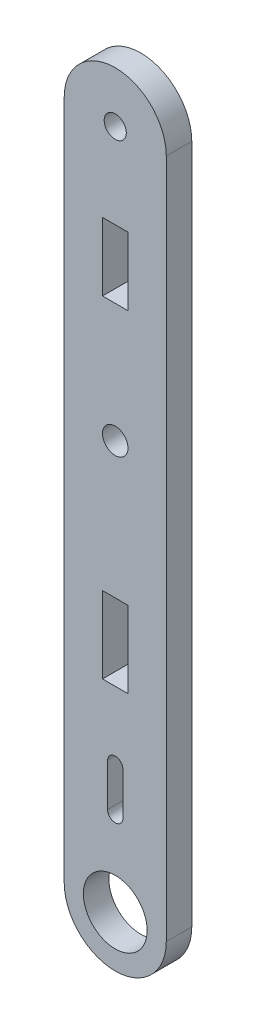
from build123d import *

# Parameters (mm, degrees)
MODEL_R             = 3.750000001
MODEL_R_2           = 1.300000002
MODEL_R_3           = 1.500000002
MODEL_W             = 3
MODEL_H             = 9
MODEL_H_2           = 8
BOSS_EXTRUDE1_DEPTH = 3


with BuildPart() as part:
    # Model → Boss-Extrude1 (new body)
    with BuildSketch(Plane.XY):
        with BuildLine():
            Line((56.05776, -3.869466211), (56.05776, 76.130633789))
            ThreePointArc((56.05776, 76.130633789), (62.05781, 82.130583788), (68.05776, 76.130533788))
            Line((68.05776, 76.130533788), (68.05776, -3.869466211))
            ThreePointArc((68.05776, -3.869466211), (62.057759999, -9.869466211), (56.05776, -3.869466211))
        make_face()
        with Locations((62.057759999, -3.869466212)):
            Circle(MODEL_R, mode=Mode.SUBTRACT)
        with Locations((62.057759998, 76.130533787)):
            Circle(MODEL_R_2, mode=Mode.SUBTRACT)
        with Locations((62.057760002, 44.130633787)):
            Circle(MODEL_R_3, mode=Mode.SUBTRACT)
        with BuildLine():
            Line((61.15776, 11.130633789), (61.15776, 6.130533789))
            ThreePointArc((61.15776, 6.130533789), (62.05776, 5.230533789), (62.95776, 6.130533789))
            Line((62.95776, 6.130533789), (62.95776, 11.130533786))
            ThreePointArc((62.95776, 11.130533786), (62.057810001, 12.030583787), (61.15776, 11.130633789))
        make_face(mode=Mode.SUBTRACT)
        with Locations((62.05776, 23.630533789)):
            Rectangle(MODEL_W, MODEL_H, mode=Mode.SUBTRACT)
        with Locations((62.05776, 62.130533789)):
            Rectangle(MODEL_W, MODEL_H_2, mode=Mode.SUBTRACT)
    extrude(amount=BOSS_EXTRUDE1_DEPTH)


solid = part.part
